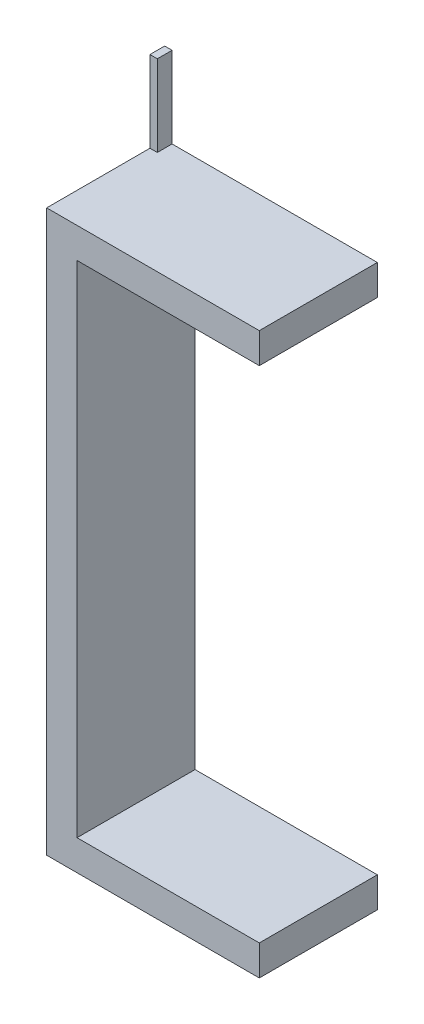
from build123d import *

# Parameters (mm, degrees)
BOSS_EXTRUDE1_DEPTH = 80
SKETCH2_W           = 5
SKETCH2_H           = 10
BOSS_EXTRUDE2_DEPTH = 55


with BuildPart() as part:
    # Sketch1 → Boss-Extrude1 (new body)
    with BuildSketch(Plane(origin=(0, 0, -60), x_dir=(-1, 0, 0), z_dir=(0, 0, -1))):
        Polygon((-144.117647059, -154.411764706), (-144.117647059, -175), (0, -175), (0, 205), (-144.117647059, 205), (-144.117647059, 184.411764706), (-20.588235294, 184.411764706), (-20.588235294, -154.411764706), align=None)
    extrude(amount=-BOSS_EXTRUDE1_DEPTH)

    # Sketch2 → Boss-Extrude2 (add)
    with BuildSketch(Plane(origin=(0, 205, 0), x_dir=(-1, 0, 0), z_dir=(0, 1, 0))):
        with Locations((-2.5, -55)):
            Rectangle(SKETCH2_W, SKETCH2_H)
    extrude(amount=BOSS_EXTRUDE2_DEPTH)


solid = part.part
